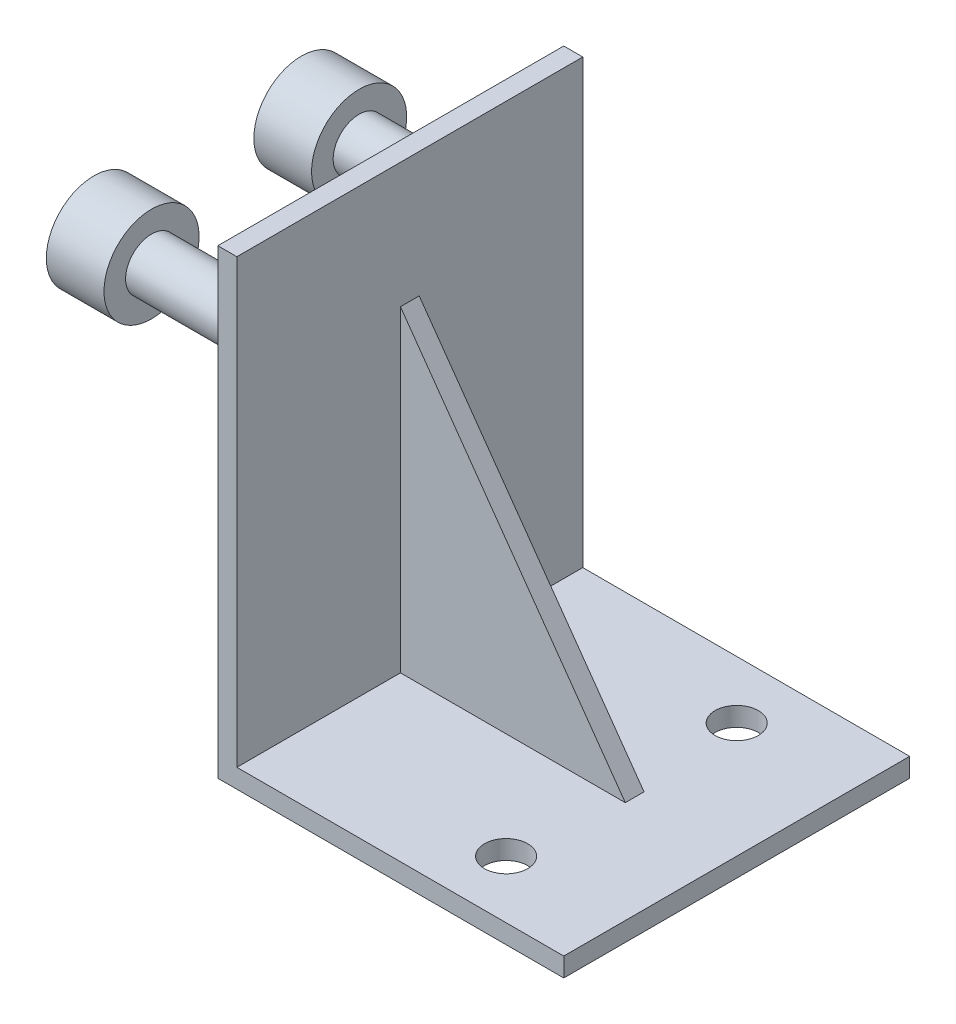
from build123d import *

# Parameters (mm, degrees)
BOSS_EXTRUDE1_DEPTH = 15.24
BOSS_EXTRUDE2_DEPTH = 0.8255
SKETCH3_R           = 1.905
CUT_EXTRUDE1_DEPTH  = 2.6764
SKETCH5_R           = 2.286
BOSS_EXTRUDE3_DEPTH = 11.938
SKETCH6_R           = 4.191
BOSS_EXTRUDE4_DEPTH = 5.08


with BuildPart() as part:
    # Sketch1 → Boss-Extrude1 (new body, symmetric)
    with BuildSketch(Plane.XY):
        Polygon((0, 0), (30.48, 0), (30.48, 1.6764), (1.6764, 1.6764), (1.6764, 40.64), (0, 40.64), align=None)
    extrude(amount=BOSS_EXTRUDE1_DEPTH, both=True)

    # Sketch2 → Boss-Extrude2 (add, symmetric)
    with BuildSketch(Plane.XY):
        Polygon((1.6764, 29.6164), (21.4884, 1.6764), (1.6764, 1.6764), align=None)
    extrude(amount=BOSS_EXTRUDE2_DEPTH, both=True)

    # Sketch3 → Cut-Extrude1 (cut, through all)
    with BuildSketch(Plane(origin=(0, 1.6764, 0), x_dir=(1, 0, 0), z_dir=(0, 1, 0))):
        with Locations((20.32, 10.16)):
            Circle(SKETCH3_R)
        with Locations((20.32, -10.16)):
            Circle(SKETCH3_R)
    extrude(amount=-CUT_EXTRUDE1_DEPTH, mode=Mode.SUBTRACT)

    # Sketch5 → Boss-Extrude3 (add)
    with BuildSketch(Plane.ZY):
        with Locations((-9.144, 30.226)):
            Circle(SKETCH5_R)
        with Locations((9.144, 30.226)):
            Circle(SKETCH5_R)
    extrude(amount=BOSS_EXTRUDE3_DEPTH)

    # Sketch6 → Boss-Extrude4 (add)
    with BuildSketch(Plane.ZY.offset(11.938)):
        with Locations((-9.144, 30.226)):
            Circle(SKETCH6_R)
        with Locations((9.144, 30.226)):
            Circle(SKETCH6_R)
    extrude(amount=BOSS_EXTRUDE4_DEPTH)


solid = part.part
